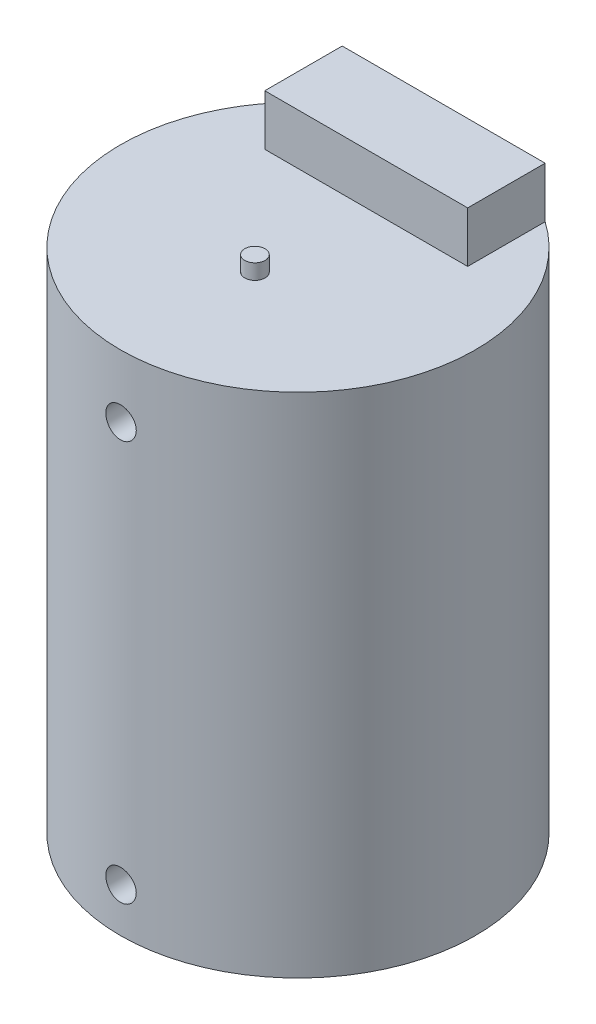
from build123d import *

# Parameters (mm, degrees)
SKETCH2_R               = 350
BOSS_EXTRUDE1_DEPTH     = 1000
SKETCH3_R               = 20
BOSS_EXTRUDE2_DEPTH     = 30
BOSS_EXTRUDE3_DEPTH     = 100
SKETCH5_R               = 30
CUT_EXTRUDE1_DEPTH      = 351
CUT_EXTRUDE1_DEPTH_BACK = 351
SKETCH6_R               = 30
CUT_EXTRUDE2_DEPTH      = 351.000000102
CUT_EXTRUDE2_DEPTH_BACK = 29


with BuildPart() as part:
    # Sketch2 → Boss-Extrude1 (new body)
    with BuildSketch(Plane(origin=(0, 0, 0), x_dir=(1, 0, 0), z_dir=(0, 1, 0))):
        Circle(SKETCH2_R)
    extrude(amount=BOSS_EXTRUDE1_DEPTH)

    # Sketch3 → Boss-Extrude2 (add)
    with BuildSketch(Plane(origin=(0, 1000, 0), x_dir=(1, 0, 0), z_dir=(0, 1, 0))):
        with Locations((0, -84.841088142)):
            Circle(SKETCH3_R)
    extrude(amount=BOSS_EXTRUDE2_DEPTH)

    # Sketch4 → Boss-Extrude3 (add)
    with BuildSketch(Plane(origin=(0, 1000, 0), x_dir=(1, 0, 0), z_dir=(0, 1, 0))):
        Polygon((0, 134.555021266), (200, 134.555021266), (200, 287.228132327), (-200, 287.228132327), (-200, 134.555021266), align=None)
    extrude(amount=BOSS_EXTRUDE3_DEPTH)

    # Sketch5 → Cut-Extrude1 (cut, two sides)
    with BuildSketch(Plane.XY) as cut_extrude1_sk:
        with Locations((0, 876.38470429)):
            Circle(SKETCH5_R)
    extrude(amount=CUT_EXTRUDE1_DEPTH, mode=Mode.SUBTRACT)
    extrude(cut_extrude1_sk.sketch, amount=-CUT_EXTRUDE1_DEPTH_BACK, mode=Mode.SUBTRACT)

    # Sketch6 → Cut-Extrude2 (cut, two sides)
    with BuildSketch(Plane.XY) as cut_extrude2_sk:
        with Locations((0, 86.895276968)):
            Circle(SKETCH6_R)
    extrude(amount=CUT_EXTRUDE2_DEPTH, mode=Mode.SUBTRACT)
    extrude(cut_extrude2_sk.sketch, amount=-CUT_EXTRUDE2_DEPTH_BACK, mode=Mode.SUBTRACT)


solid = part.part
